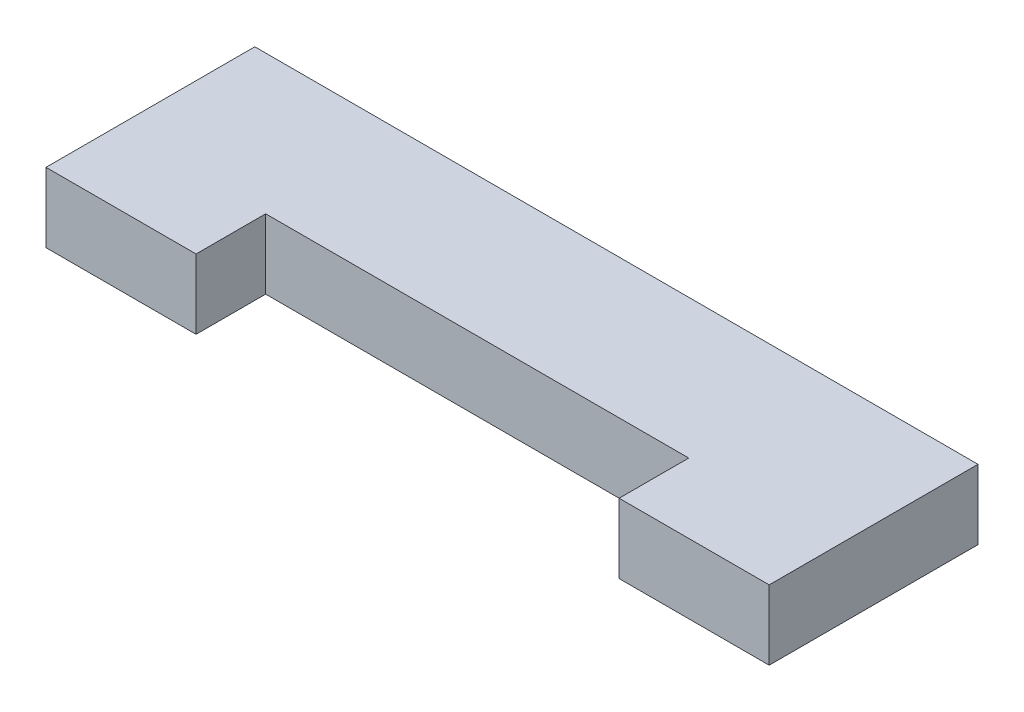
from build123d import *

# Parameters (mm, degrees)
BOSS_EXTRUDE1_DEPTH = 3.85


with BuildPart() as part:
    # Sketch1 → Boss-Extrude1 (new body)
    with BuildSketch(Plane(origin=(0, 0, 0), x_dir=(1, 0, 0), z_dir=(0, 1, 0))):
        Polygon((-20, -3.85), (-20, -7.7), (-11.7, -7.7), (-11.7, -3.85), (11.7, -3.85), (11.7, -7.7), (20, -7.7), (20, -3.85), (20, 3.85), (-20, 3.85), align=None)
    extrude(amount=BOSS_EXTRUDE1_DEPTH)


solid = part.part
